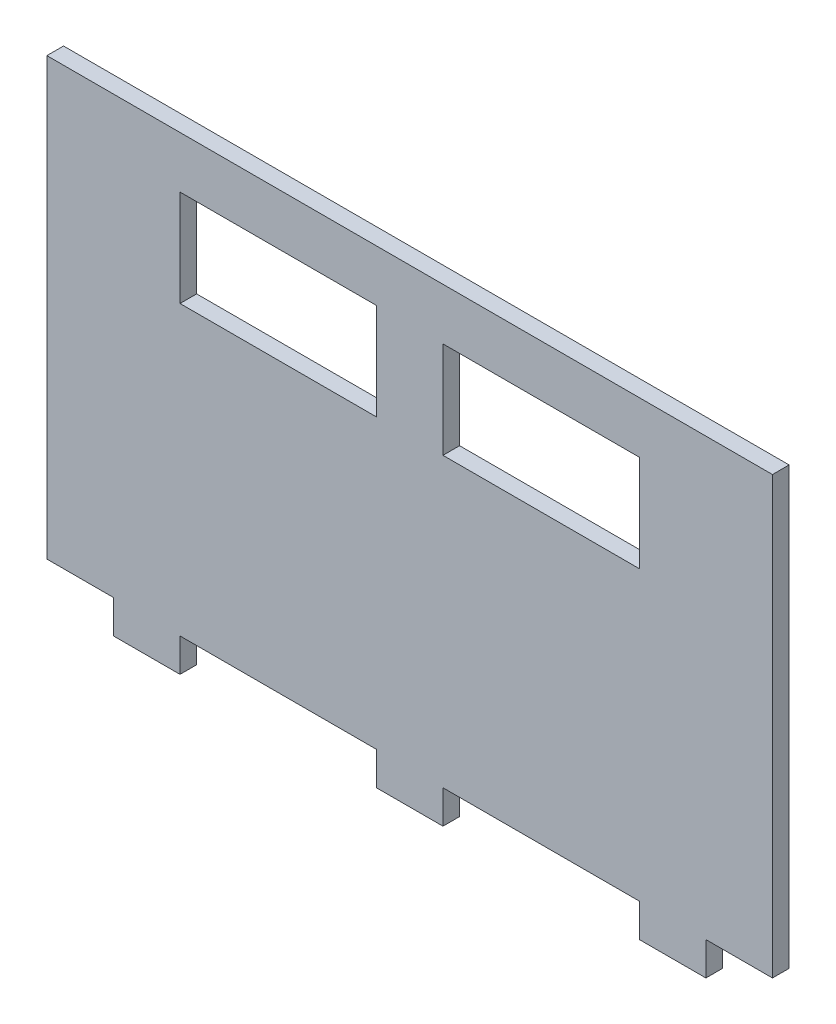
from build123d import *

# Parameters (mm, degrees)
SKETCH1_W           = 218
SKETCH1_H           = 131
SKETCH1_W_2         = 59
SKETCH1_H_2         = 29
SKETCH1_W_3         = 20
SKETCH1_H_3         = 10
BOSS_EXTRUDE1_DEPTH = 5


with BuildPart() as part:
    # Sketch1 → Boss-Extrude1 (new body)
    with BuildSketch(Plane.XY):
        Rectangle(SKETCH1_W, SKETCH1_H)
        with Locations((39.5, 35.5)):
            Rectangle(SKETCH1_W_2, SKETCH1_H_2, mode=Mode.SUBTRACT)
        with Locations((-39.5, 35.5)):
            Rectangle(SKETCH1_W_2, SKETCH1_H_2, mode=Mode.SUBTRACT)
        with Locations((-79, -70.5)):
            Rectangle(SKETCH1_W_3, SKETCH1_H_3)
        with Locations((0, -70.5)):
            Rectangle(SKETCH1_W_3, SKETCH1_H_3)
        with Locations((79, -70.5)):
            Rectangle(SKETCH1_W_3, SKETCH1_H_3)
    extrude(amount=BOSS_EXTRUDE1_DEPTH)


solid = part.part
